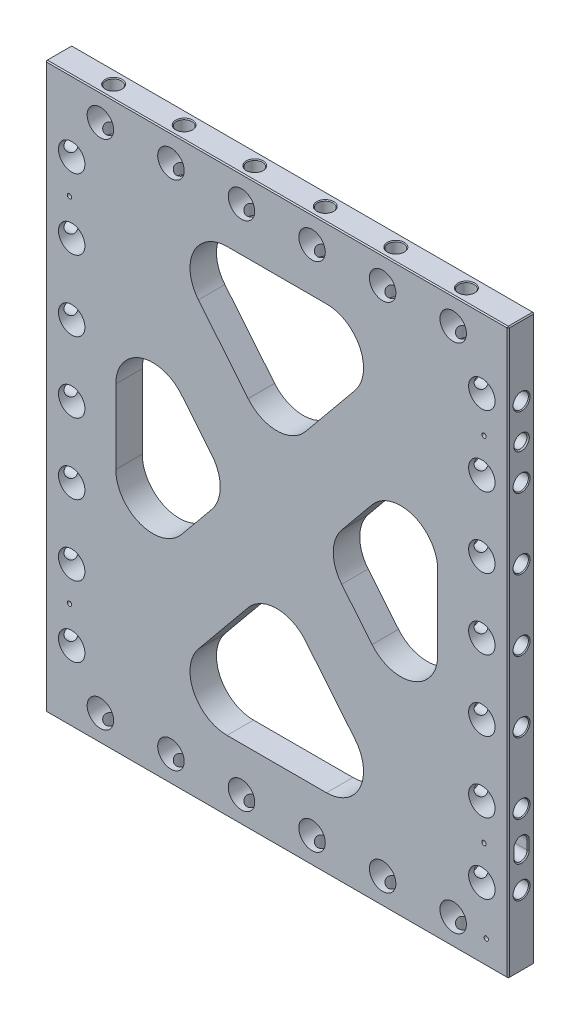
from build123d import *

# Parameters (mm, degrees)
SKETCH2_W                               = 333.375
SKETCH2_H                               = 406.4
EXTRUDE1_DEPTH                          = 9.525
TRIANGLES_CUT_EXTRUDE2_DEPTH            = 20.05
TRIANGLES_FILLET1_R                     = 26.67
F_3_4_0_75_DIAMETER_HOLE1_D             = 19.05
LPATTERN3_COUNT                         = 4
LPATTERN3_PITCH                         = 50.8
LPATTERN3_COL_COUNT                     = 4
LPATTERN3_COL_PITCH                     = 50.8
MIRROR1_COPY_1_D                        = 19.05
MIRROR1_COPY_2_D                        = 19.05
MIRROR1_COPY_3_D                        = 19.05
MIRROR1_COPY_7_D                        = 19.05
MIRROR1_COPY_8_D                        = 19.05
MIRROR1_COPY_9_D                        = 19.05
F_3_4_0_75_DIAMETER_HOLE2_D             = 19.05
F_7_16_0_4375_DIAMETER_HOLE2_AT_2_COUNT = 2
F_7_16_0_4375_DIAMETER_HOLE2_AT_2_PITCH = 50.8
F_7_16_0_4375_DIAMETER_HOLE2_AT_3_COUNT = 2
F_7_16_0_4375_DIAMETER_HOLE2_AT_3_PITCH = 50.8
F_7_16_0_4375_DIAMETER_HOLE2_AT_4_COUNT = 2
F_7_16_0_4375_DIAMETER_HOLE2_AT_4_PITCH = 101.6
F_7_16_0_4375_DIAMETER_HOLE2_AT_5_COUNT = 2
F_7_16_0_4375_DIAMETER_HOLE2_AT_5_PITCH = 101.6
F_7_16_0_4375_DIAMETER_HOLE2_AT_6_COUNT = 2
F_7_16_0_4375_DIAMETER_HOLE2_AT_6_PITCH = 152.4
F_3_8_0_376_PIN_LOCATE1_D               = 9.5504
F_3_8_0_376_PIN_LOCATE1_DEPTH           = 19.05
F_3_8_0_376_PIN_LOCATE1_CSINK_D         = 11.176
F_3_8_0_376_PIN_LOCATE1_CSINK_ANGLE     = 82
F_3_8_0_376_PIN_LOCATE1_TIP             = 2.869229628
F_3_8_0_376_PIN_LOCATE2_D               = 9.5504
F_3_8_0_376_PIN_LOCATE2_DEPTH           = 19.05
F_3_8_0_376_PIN_LOCATE2_CSINK_D         = 11.176
F_3_8_0_376_PIN_LOCATE2_CSINK_ANGLE     = 82
F_3_8_0_376_PIN_LOCATE2_TIP             = 2.869229628
SLOT_LOCATE1_DEPTH                      = 19.05
CHAMFER1_SIZE                           = 0.762
SLOT_LOCATE2_DEPTH                      = 19.05
CHAMFER2_SIZE                           = 0.762
F_1_8_0_125_DIAMETER_HOLE1_D            = 3.175
F_1_8_0_125_DIAMETER_HOLE1_DEPTH        = 9.525
F_1_8_0_125_DIAMETER_HOLE1_TIP          = 0.953866233
CHAMFER3_SIZE                           = 0.762


with BuildPart() as part:
    # Sketch2 → Extrude1 (new body, symmetric)
    with BuildSketch(Plane.XY):
        Rectangle(SKETCH2_W, SKETCH2_H)
    extrude(amount=EXTRUDE1_DEPTH, both=True)

    # Sketch8 → Triangles -- Cut-Extrude2 (cut, through all)
    with BuildSketch(Plane.XY.offset(9.525)):
        Polygon((-115.8875, 101.223442137), (-32.852645122, 0), (-115.8875, -101.223442137), align=None)
        Polygon((-92.162979878, 152.4), (0, 40.048938815), (92.162979878, 152.4), align=None)
        Polygon((115.8875, 101.223442137), (115.8875, -101.223442137), (32.852645122, 0), align=None)
        Polygon((0, -40.048938815), (-92.162979878, -152.4), (92.162979878, -152.4), align=None)
    extrude(amount=-TRIANGLES_CUT_EXTRUDE2_DEPTH, mode=Mode.SUBTRACT)

    # Triangles -- Fillet1
    triangles_fillet1_edges = [part.edges().sort_by_distance(p)[0] for p in [
        (-115.8875, -101.223442137, 0),
        (-115.8875, 101.223442137, 0),
        (-32.852645122, 0, 0),
        (-92.162979878, 152.4, 0),
        (92.162979878, 152.4, 0),
        (0, 40.048938815, 0),
        (32.852645122, 0, 0),
        (115.8875, 101.223442137, 0),
        (115.8875, -101.223442137, 0),
        (0, -40.048938815, 0),
        (92.162979878, -152.4, 0),
        (-92.162979878, -152.4, 0),
    ]]
    fillet(triangles_fillet1_edges, radius=TRIANGLES_FILLET1_R)

    # 3/4 (0.75) Diameter Hole1 (through all)
    with Locations(Plane.XY.offset(9.525)):
        with Locations((-147.6375, 0)):
            f_3_4_0_75_diameter_hole1 = Hole(F_3_4_0_75_DIAMETER_HOLE1_D / 2)

    # Sketch5 → 7/16 (0.4375) Diameter Hole1 (revolve, cut)
    with BuildSketch(Plane(origin=(-166.6875, 0, 0), x_dir=(0, 0, 1), z_dir=(0, 1, 0))):
        Polygon((0, 0), (0, 38.263531814), (5.55625, 34.925), (5.55625, 0.620911348), (6.096, 0), align=None)
    f_7_16_0_4375_diameter_hole1 = revolve(axis=Axis((-173.0375, 0, 0), (1, 0, 0)), mode=Mode.SUBTRACT)

    # LPattern3: 3/4 (0.75) Diameter Hole1, 7/16 (0.4375) Diameter Hole1 ×4
    with Locations(*[(0, i * LPATTERN3_PITCH, 0) for i in range(1, LPATTERN3_COUNT)]):
        add(f_3_4_0_75_diameter_hole1, mode=Mode.SUBTRACT)
        add(f_7_16_0_4375_diameter_hole1, mode=Mode.SUBTRACT)

    # LPattern3 col: 3/4 (0.75) Diameter Hole1, 7/16 (0.4375) Diameter Hole1 ×4
    with Locations(*[(0, -i * LPATTERN3_COL_PITCH, 0) for i in range(1, LPATTERN3_COL_COUNT)]):
        add(f_3_4_0_75_diameter_hole1, mode=Mode.SUBTRACT)
        add(f_7_16_0_4375_diameter_hole1, mode=Mode.SUBTRACT)

    # Mirror1: 3/4 (0.75) Diameter Hole1, 7/16 (0.4375) Diameter Hole1 across plane
    add(f_3_4_0_75_diameter_hole1.mirror(Plane(origin=(0, 0, 0), x_dir=(0, 0, 1), z_dir=(1, 0, 0))), mode=Mode.SUBTRACT)
    add(f_7_16_0_4375_diameter_hole1.mirror(Plane(origin=(0, 0, 0), x_dir=(0, 0, 1), z_dir=(1, 0, 0))), mode=Mode.SUBTRACT)

    # Mirror1 copy 1 (through all)
    with Locations(Plane(origin=(0, 50.8, 9.525), x_dir=(-1, 0, 0), z_dir=(0, 0, 1))):
        with Locations((-147.6375, 0)):
            Hole(MIRROR1_COPY_1_D / 2)

    # Mirror1 copy 2 (through all)
    with Locations(Plane(origin=(0, 101.6, 9.525), x_dir=(-1, 0, 0), z_dir=(0, 0, 1))):
        with Locations((-147.6375, 0)):
            Hole(MIRROR1_COPY_2_D / 2)

    # Mirror1 copy 3 (through all)
    with Locations(Plane(origin=(0, 152.4, 9.525), x_dir=(-1, 0, 0), z_dir=(0, 0, 1))):
        with Locations((-147.6375, 0)):
            Hole(MIRROR1_COPY_3_D / 2)

    # Mirror1 copy 4 sketch → Mirror1 copy 4 (revolve, cut)
    with BuildSketch(Plane(origin=(166.6875, 50.8, 0), x_dir=(0, 0, 1), z_dir=(0, 1, 0))):
        Polygon((0, 0), (0, -38.263531814), (5.55625, -34.925), (5.55625, -0.620911348), (6.096, 0), align=None)
    revolve(axis=Axis((173.0375, 50.8, 0), (1, 0, 0)), mode=Mode.SUBTRACT)

    # Mirror1 copy 5 sketch → Mirror1 copy 5 (revolve, cut)
    with BuildSketch(Plane(origin=(166.6875, 101.6, 0), x_dir=(0, 0, 1), z_dir=(0, 1, 0))):
        Polygon((0, 0), (0, -38.263531814), (5.55625, -34.925), (5.55625, -0.620911348), (6.096, 0), align=None)
    revolve(axis=Axis((173.0375, 101.6, 0), (1, 0, 0)), mode=Mode.SUBTRACT)

    # Mirror1 copy 6 sketch → Mirror1 copy 6 (revolve, cut)
    with BuildSketch(Plane(origin=(166.6875, 152.4, 0), x_dir=(0, 0, 1), z_dir=(0, 1, 0))):
        Polygon((0, 0), (0, -38.263531814), (5.55625, -34.925), (5.55625, -0.620911348), (6.096, 0), align=None)
    revolve(axis=Axis((173.0375, 152.4, 0), (1, 0, 0)), mode=Mode.SUBTRACT)

    # Mirror1 copy 7 (through all)
    with Locations(Plane(origin=(0, -50.8, 9.525), x_dir=(-1, 0, 0), z_dir=(0, 0, 1))):
        with Locations((-147.6375, 0)):
            Hole(MIRROR1_COPY_7_D / 2)

    # Mirror1 copy 8 (through all)
    with Locations(Plane(origin=(0, -101.6, 9.525), x_dir=(-1, 0, 0), z_dir=(0, 0, 1))):
        with Locations((-147.6375, 0)):
            Hole(MIRROR1_COPY_8_D / 2)

    # Mirror1 copy 9 (through all)
    with Locations(Plane(origin=(0, -152.4, 9.525), x_dir=(-1, 0, 0), z_dir=(0, 0, 1))):
        with Locations((-147.6375, 0)):
            Hole(MIRROR1_COPY_9_D / 2)

    # Mirror1 copy 10 sketch → Mirror1 copy 10 (revolve, cut)
    with BuildSketch(Plane(origin=(166.6875, -50.8, 0), x_dir=(0, 0, 1), z_dir=(0, 1, 0))):
        Polygon((0, 0), (0, -38.263531814), (5.55625, -34.925), (5.55625, -0.620911348), (6.096, 0), align=None)
    revolve(axis=Axis((173.0375, -50.8, 0), (1, 0, 0)), mode=Mode.SUBTRACT)

    # Mirror1 copy 11 sketch → Mirror1 copy 11 (revolve, cut)
    with BuildSketch(Plane(origin=(166.6875, -101.6, 0), x_dir=(0, 0, 1), z_dir=(0, 1, 0))):
        Polygon((0, 0), (0, -38.263531814), (5.55625, -34.925), (5.55625, -0.620911348), (6.096, 0), align=None)
    revolve(axis=Axis((173.0375, -101.6, 0), (1, 0, 0)), mode=Mode.SUBTRACT)

    # Mirror1 copy 12 sketch → Mirror1 copy 12 (revolve, cut)
    with BuildSketch(Plane(origin=(166.6875, -152.4, 0), x_dir=(0, 0, 1), z_dir=(0, 1, 0))):
        Polygon((0, 0), (0, -38.263531814), (5.55625, -34.925), (5.55625, -0.620911348), (6.096, 0), align=None)
    revolve(axis=Axis((173.0375, -152.4, 0), (1, 0, 0)), mode=Mode.SUBTRACT)

    # 3/4 (0.75) Diameter Hole2 (through all)
    with Locations(Plane.XY.offset(9.525)):
        with Locations((-25.4, -184.15), (25.4, -184.15), (76.2, -184.15), (-76.2, -184.15), (-127, -184.15), (127, -184.15)):
            f_3_4_0_75_diameter_hole2 = Hole(F_3_4_0_75_DIAMETER_HOLE2_D / 2)

    # Sketch12 → 7/16 (0.4375) Diameter Hole2 (revolve, cut)
    with BuildSketch(Plane(origin=(-25.4, -203.2, 0), x_dir=(0, 0, -1), z_dir=(1, 0, 0))):
        Polygon((0, 0), (0, 38.263531814), (5.55625, 34.925), (5.55625, 0.620911348), (6.096, 0), align=None)
    f_7_16_0_4375_diameter_hole2 = revolve(axis=Axis((-25.4, -209.55, 0), (0, 1, 0)), mode=Mode.SUBTRACT)

    # 7/16 (0.4375) Diameter Hole2 at 2: 7/16 (0.4375) Diameter Hole2 ×2
    with Locations(*[(-i * F_7_16_0_4375_DIAMETER_HOLE2_AT_2_PITCH, 0, 0) for i in range(1, F_7_16_0_4375_DIAMETER_HOLE2_AT_2_COUNT)]):
        add(f_7_16_0_4375_diameter_hole2, mode=Mode.SUBTRACT)

    # 7/16 (0.4375) Diameter Hole2 at 3: 7/16 (0.4375) Diameter Hole2 ×2
    with Locations(*[(i * F_7_16_0_4375_DIAMETER_HOLE2_AT_3_PITCH, 0, 0) for i in range(1, F_7_16_0_4375_DIAMETER_HOLE2_AT_3_COUNT)]):
        add(f_7_16_0_4375_diameter_hole2, mode=Mode.SUBTRACT)

    # 7/16 (0.4375) Diameter Hole2 at 4: 7/16 (0.4375) Diameter Hole2 ×2
    with Locations(*[(i * F_7_16_0_4375_DIAMETER_HOLE2_AT_4_PITCH, 0, 0) for i in range(1, F_7_16_0_4375_DIAMETER_HOLE2_AT_4_COUNT)]):
        add(f_7_16_0_4375_diameter_hole2, mode=Mode.SUBTRACT)

    # 7/16 (0.4375) Diameter Hole2 at 5: 7/16 (0.4375) Diameter Hole2 ×2
    with Locations(*[(-i * F_7_16_0_4375_DIAMETER_HOLE2_AT_5_PITCH, 0, 0) for i in range(1, F_7_16_0_4375_DIAMETER_HOLE2_AT_5_COUNT)]):
        add(f_7_16_0_4375_diameter_hole2, mode=Mode.SUBTRACT)

    # 7/16 (0.4375) Diameter Hole2 at 6: 7/16 (0.4375) Diameter Hole2 ×2
    with Locations(*[(i * F_7_16_0_4375_DIAMETER_HOLE2_AT_6_PITCH, 0, 0) for i in range(1, F_7_16_0_4375_DIAMETER_HOLE2_AT_6_COUNT)]):
        add(f_7_16_0_4375_diameter_hole2, mode=Mode.SUBTRACT)

    # Mirror2: 3/4 (0.75) Diameter Hole2, 7/16 (0.4375) Diameter Hole2 across plane
    add(f_3_4_0_75_diameter_hole2.mirror(Plane.ZX), mode=Mode.SUBTRACT)
    add(f_7_16_0_4375_diameter_hole2.mirror(Plane.ZX), mode=Mode.SUBTRACT)

    # Mirror2 copy 1 sketch → Mirror2 copy 1 (revolve, cut)
    with BuildSketch(Plane(origin=(-76.2, 203.2, 0), x_dir=(0, 0, -1), z_dir=(1, 0, 0))):
        Polygon((0, 0), (0, -38.263531814), (5.55625, -34.925), (5.55625, -0.620911348), (6.096, 0), align=None)
    revolve(axis=Axis((-76.2, 209.55, 0), (0, 1, 0)), mode=Mode.SUBTRACT)

    # Mirror2 copy 2 sketch → Mirror2 copy 2 (revolve, cut)
    with BuildSketch(Plane(origin=(25.4, 203.2, 0), x_dir=(0, 0, -1), z_dir=(1, 0, 0))):
        Polygon((0, 0), (0, -38.263531814), (5.55625, -34.925), (5.55625, -0.620911348), (6.096, 0), align=None)
    revolve(axis=Axis((25.4, 209.55, 0), (0, 1, 0)), mode=Mode.SUBTRACT)

    # Mirror2 copy 3 sketch → Mirror2 copy 3 (revolve, cut)
    with BuildSketch(Plane(origin=(76.2, 203.2, 0), x_dir=(0, 0, -1), z_dir=(1, 0, 0))):
        Polygon((0, 0), (0, -38.263531814), (5.55625, -34.925), (5.55625, -0.620911348), (6.096, 0), align=None)
    revolve(axis=Axis((76.2, 209.55, 0), (0, 1, 0)), mode=Mode.SUBTRACT)

    # Mirror2 copy 4 sketch → Mirror2 copy 4 (revolve, cut)
    with BuildSketch(Plane(origin=(-127, 203.2, 0), x_dir=(0, 0, -1), z_dir=(1, 0, 0))):
        Polygon((0, 0), (0, -38.263531814), (5.55625, -34.925), (5.55625, -0.620911348), (6.096, 0), align=None)
    revolve(axis=Axis((-127, 209.55, 0), (0, 1, 0)), mode=Mode.SUBTRACT)

    # Mirror2 copy 5 sketch → Mirror2 copy 5 (revolve, cut)
    with BuildSketch(Plane(origin=(127, 203.2, 0), x_dir=(0, 0, -1), z_dir=(1, 0, 0))):
        Polygon((0, 0), (0, -38.263531814), (5.55625, -34.925), (5.55625, -0.620911348), (6.096, 0), align=None)
    revolve(axis=Axis((127, 209.55, 0), (0, 1, 0)), mode=Mode.SUBTRACT)

    # Sketch14 → 3/8 (0.375) Pin Hole1 (revolve, cut)
    with BuildSketch(Plane(origin=(150.8125, -203.2, 0), x_dir=(0, 0, -1), z_dir=(1, 0, 0))):
        Polygon((0, 0), (0, 21.911598698), (4.7625, 19.05), (4.7625, 3.175), (4.7879, 3.175), (4.7879, 0.628216187), (5.334, 0), align=None)
    revolve(axis=Axis((150.8125, -209.55, 0), (0, 1, 0)), mode=Mode.SUBTRACT)

    # 3/8 (0.376) Pin Locate1
    with Locations(Plane.ZY.offset(166.6875)):
        with Locations((0, 127)):
            CounterSinkHole(F_3_8_0_376_PIN_LOCATE1_D / 2, F_3_8_0_376_PIN_LOCATE1_CSINK_D / 2, depth=F_3_8_0_376_PIN_LOCATE1_DEPTH, counter_sink_angle=F_3_8_0_376_PIN_LOCATE1_CSINK_ANGLE)
            with Locations((0, 0, -(F_3_8_0_376_PIN_LOCATE1_DEPTH + F_3_8_0_376_PIN_LOCATE1_TIP / 2))):  # 118° drill point
                Cone(0, F_3_8_0_376_PIN_LOCATE1_D / 2, F_3_8_0_376_PIN_LOCATE1_TIP, mode=Mode.SUBTRACT)

    # 3/8 (0.376) Pin Locate2
    with Locations(Plane(origin=(166.6875, 0, 0), x_dir=(0, 0, -1), z_dir=(1, 0, 0))):
        with Locations((0, 127)):
            CounterSinkHole(F_3_8_0_376_PIN_LOCATE2_D / 2, F_3_8_0_376_PIN_LOCATE2_CSINK_D / 2, depth=F_3_8_0_376_PIN_LOCATE2_DEPTH, counter_sink_angle=F_3_8_0_376_PIN_LOCATE2_CSINK_ANGLE)
            with Locations((0, 0, -(F_3_8_0_376_PIN_LOCATE2_DEPTH + F_3_8_0_376_PIN_LOCATE2_TIP / 2))):  # 118° drill point
                Cone(0, F_3_8_0_376_PIN_LOCATE2_D / 2, F_3_8_0_376_PIN_LOCATE2_TIP, mode=Mode.SUBTRACT)

    # Sketch20 → Slot Locate1 (cut)
    with BuildSketch(Plane.ZY.offset(166.6875)):
        with BuildLine():
            Line((4.7752, -130.175), (4.7752, -123.825))
            ThreePointArc((4.7752, -123.825), (0, -119.0498), (-4.7752, -123.825))
            Line((-4.7752, -123.825), (-4.7752, -130.175))
            ThreePointArc((-4.7752, -130.175), (0, -134.9502), (4.7752, -130.175))
        make_face()
    extrude(amount=-SLOT_LOCATE1_DEPTH, mode=Mode.SUBTRACT)

    # Chamfer1
    chamfer1_edges = [part.edges().sort_by_distance(p)[0] for p in [
        (-166.6875, -134.9502, 0),
        (-166.6875, -127, 4.7752),
        (-166.6875, -119.0498, 0),
        (-166.6875, -127, -4.7752),
    ]]
    chamfer(chamfer1_edges, length=CHAMFER1_SIZE)

    # Sketch21 → Slot Locate2 (cut)
    with BuildSketch(Plane(origin=(166.6875, 0, 0), x_dir=(0, 0, -1), z_dir=(1, 0, 0))):
        with BuildLine():
            Line((-4.7752, -123.825), (-4.7752, -130.175))
            ThreePointArc((-4.7752, -130.175), (0, -134.9502), (4.7752, -130.175))
            Line((4.7752, -130.175), (4.7752, -123.825))
            ThreePointArc((4.7752, -123.825), (0, -119.0498), (-4.7752, -123.825))
        make_face()
    extrude(amount=-SLOT_LOCATE2_DEPTH, mode=Mode.SUBTRACT)

    # Chamfer2
    chamfer2_edges = [part.edges().sort_by_distance(p)[0] for p in [
        (166.6875, -119.0498, 0),
        (166.6875, -127, 4.7752),
        (166.6875, -134.9502, 0),
        (166.6875, -127, -4.7752),
    ]]
    chamfer(chamfer2_edges, length=CHAMFER2_SIZE)

    # 1/8 (0.125) Diameter Hole1
    with Locations(Plane.XY.offset(9.525)):
        with Locations((150.8125, -185.7375), (149.225, -127), (149.225, 127), (-149.225, 127), (-149.225, -127)):
            Hole(F_1_8_0_125_DIAMETER_HOLE1_D / 2, depth=F_1_8_0_125_DIAMETER_HOLE1_DEPTH)
            with Locations((0, 0, -(F_1_8_0_125_DIAMETER_HOLE1_DEPTH + F_1_8_0_125_DIAMETER_HOLE1_TIP / 2))):  # 118° drill point
                Cone(0, F_1_8_0_125_DIAMETER_HOLE1_D / 2, F_1_8_0_125_DIAMETER_HOLE1_TIP, mode=Mode.SUBTRACT)

    # Chamfer3
    chamfer3_edges = [part.edges().sort_by_distance(p)[0] for p in [
        (166.6875, 0, 9.525),
        (0, 203.2, 9.525),
        (-166.6875, 0, 9.525),
        (0, 203.2, -9.525),
        (166.6875, 0, -9.525),
        (0, -203.2, -9.525),
        (-166.6875, 0, -9.525),
        (0, -203.2, 9.525),
        (-166.6875, 203.2, 0),
        (166.6875, 203.2, 0),
        (166.6875, -203.2, 0),
        (-166.6875, -203.2, 0),
    ]]
    chamfer(chamfer3_edges, length=CHAMFER3_SIZE)


solid = part.part
